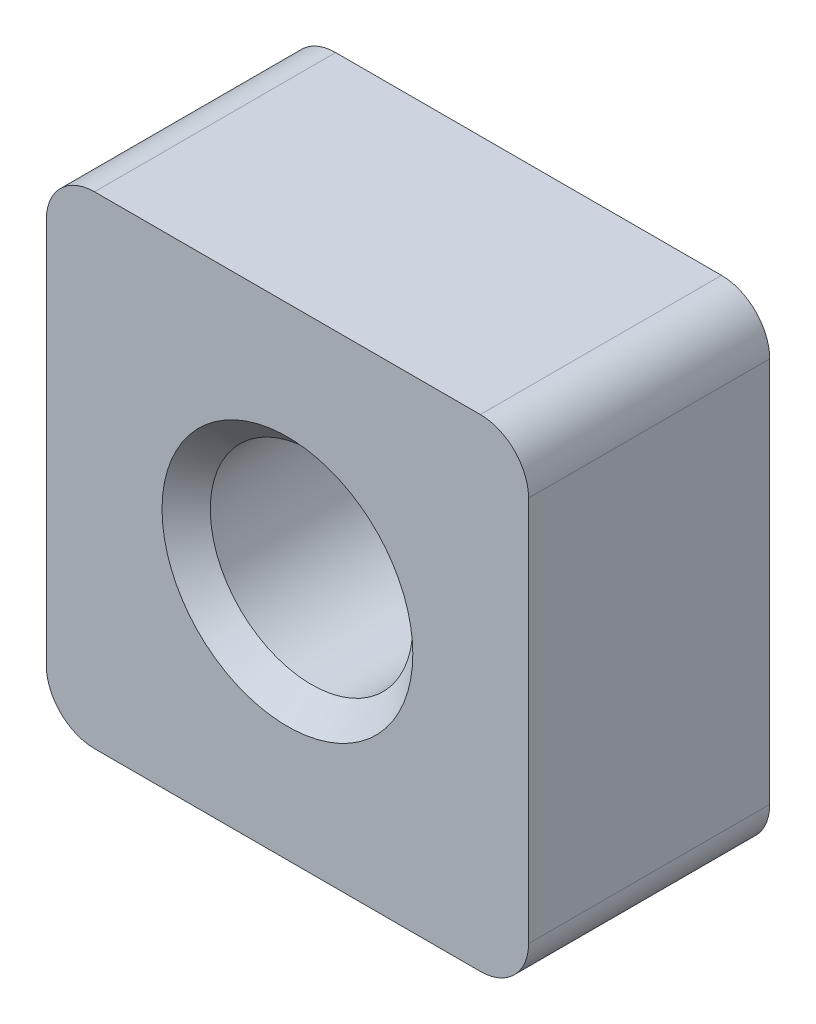
from build123d import *

# Parameters (mm, degrees)
SKETCH_1_W      = 10
SKETCH_1_H      = 10
EXTRUDE_1_DEPTH = 5
FILLET_1_R      = 1


with BuildPart() as part:
    # Эскиз1 → Бобышка-Вытянуть1 (new body)
    with BuildSketch(Plane.XY):
        Rectangle(SKETCH_1_W, SKETCH_1_H)
    extrude(amount=EXTRUDE_1_DEPTH)

    # Эскиз3 → Отверстие обработанное метчиком M51 (revolve, cut)
    with BuildSketch(Plane(origin=(0, 0, 5), x_dir=(0, -1, 0), z_dir=(1, 0, 0))):
        Polygon((0, 0), (0, 5), (2.6, 5), (2.1, 4.5), (2.1, 0.5), (2.6, 0), align=None)
    revolve(axis=Axis((0, 0, 11.35), (0, 0, -1)), mode=Mode.SUBTRACT)

    # Скругление1
    fillet_1_edges = [part.edges().sort_by_distance(p)[0] for p in [
        (5, -5, 2.5),
        (-5, -5, 2.5),
        (-5, 5, 2.5),
        (5, 5, 2.5),
    ]]
    fillet(fillet_1_edges, radius=FILLET_1_R)


solid = part.part
